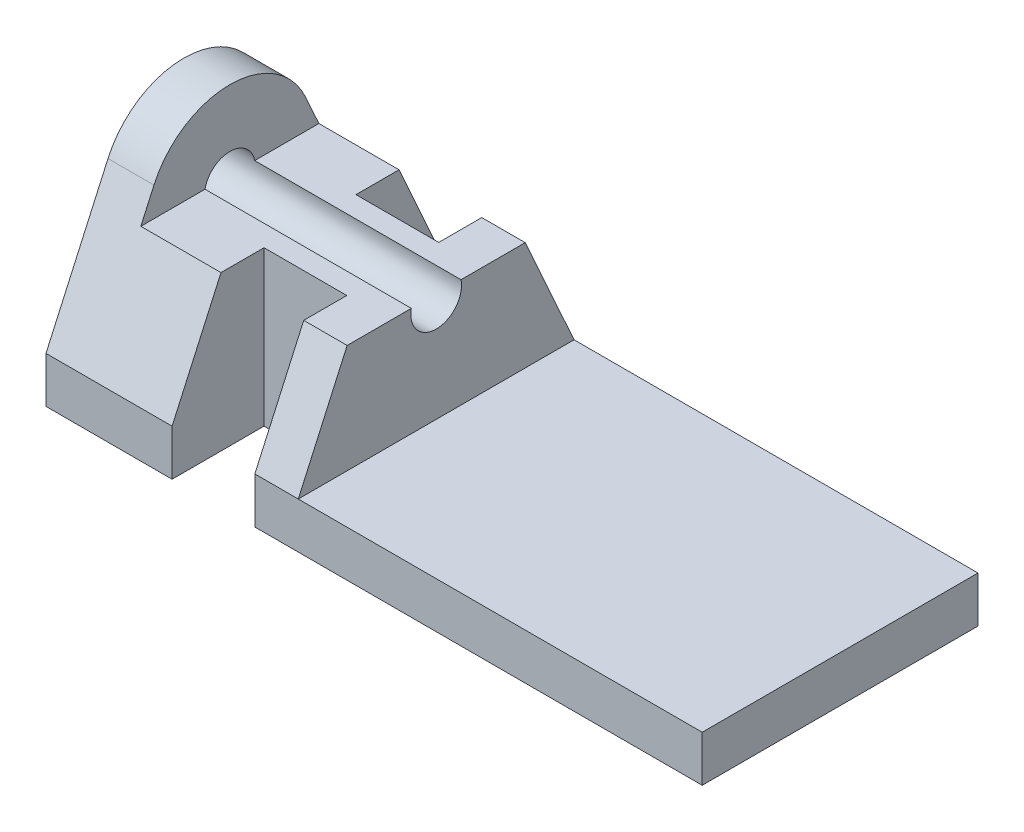
from build123d import *

# Parameters (mm, degrees)
SKETCH5_W                = 33.357089
SKETCH5_H                = 38.1
BOSS_EXTRUDE2_DEPTH      = 20.8
BOSS_EXTRUDE2_DEPTH_BACK = 69.85
SKETCH6_W                = 84.3
SKETCH6_H                = 27.007089
CUT_EXTRUDE1_DEPTH       = 39.1
SKETCH7_R                = 3.5
CUT_EXTRUDE2_DEPTH       = 21.8
CUT_EXTRUDE2_DEPTH_BACK  = 70.85
CUT_EXTRUDE3_DEPTH       = 70.85
SKETCH9_W                = 28.5
SKETCH9_H                = 38.1
BOSS_EXTRUDE3_DEPTH      = 15
CUT_EXTRUDE4_DEPTH       = 70.85
SKETCH11_R               = 3.5
CUT_EXTRUDE5_DEPTH       = 70.85
SKETCH13_W               = 11.43
SKETCH13_H               = 25.4
CUT_EXTRUDE6_DEPTH       = 26.807089
CUT_EXTRUDE6_DEPTH_BACK  = 7.35


with BuildPart() as part:
    # Sketch5 → Boss-Extrude2 (new body, two sides)
    with BuildSketch(Plane(origin=(0, 0, 0), x_dir=(0, -1, 0), z_dir=(1, 0, 0))) as boss_extrude2_sk:
        with Locations((-10.3285445, 0)):
            Rectangle(SKETCH5_W, SKETCH5_H)
    extrude(amount=BOSS_EXTRUDE2_DEPTH)
    extrude(boss_extrude2_sk.sketch, amount=-BOSS_EXTRUDE2_DEPTH_BACK)

    # Sketch6 → Cut-Extrude1 (cut, through all)
    with BuildSketch(Plane.XY.offset(19.05)):
        with Locations((-21.35, 13.5035445)):
            Rectangle(SKETCH6_W, SKETCH6_H)
    extrude(amount=-CUT_EXTRUDE1_DEPTH, mode=Mode.SUBTRACT)

    # Sketch7 → Cut-Extrude2 (cut, two sides)
    with BuildSketch(Plane(origin=(0, 0, 0), x_dir=(0, 0, -1), z_dir=(1, 0, 0))) as cut_extrude2_sk:
        with Locations((0, 14.307089)):
            Circle(SKETCH7_R)
    extrude(amount=CUT_EXTRUDE2_DEPTH, mode=Mode.SUBTRACT)
    extrude(cut_extrude2_sk.sketch, amount=-CUT_EXTRUDE2_DEPTH_BACK, mode=Mode.SUBTRACT)

    # Sketch8 → Cut-Extrude3 (cut, through all)
    with BuildSketch(Plane(origin=(0, 0, 0), x_dir=(0, 0, -1), z_dir=(1, 0, 0))):
        with BuildLine():
            Line((19.05, 0), (10.486875479, 19.026775715))
            ThreePointArc((10.486875479, 19.026775715), (0, 25.807089), (-10.486875479, 19.026775715))
            Line((-10.486875479, 19.026775715), (-19.05, 0))
            Line((-19.05, 0), (-19.05, 27.007089))
            Line((-19.05, 27.007089), (19.05, 27.007089))
            Line((19.05, 27.007089), (19.05, 0))
        make_face()
    extrude(amount=-CUT_EXTRUDE3_DEPTH, mode=Mode.SUBTRACT)

    # Sketch9 → Boss-Extrude3 (add)
    with BuildSketch(Plane(origin=(0, 0, 0), x_dir=(1, 0, 0), z_dir=(0, 1, 0))):
        with Locations((-49.25, 0)):
            Rectangle(SKETCH9_W, SKETCH9_H)
    extrude(amount=BOSS_EXTRUDE3_DEPTH)

    # Sketch10 → Cut-Extrude4 (cut, through all)
    with BuildSketch(Plane(origin=(0, 0, 0), x_dir=(0, 0, -1), z_dir=(1, 0, 0))):
        Polygon((19.05, 42.328016658), (19.05, 0), (0, 42.328016658), align=None)
        Polygon((-19.05, 42.328016658), (0, 42.328016658), (-19.05, 0), align=None)
    extrude(amount=-CUT_EXTRUDE4_DEPTH, mode=Mode.SUBTRACT)

    # Sketch11 → Cut-Extrude5 (cut, through all)
    with BuildSketch(Plane(origin=(0, 0, 0), x_dir=(0, 0, -1), z_dir=(1, 0, 0))):
        with Locations((0, 14.307089)):
            Circle(SKETCH11_R)
    extrude(amount=-CUT_EXTRUDE5_DEPTH, mode=Mode.SUBTRACT)

    # Sketch13 → Cut-Extrude6 (cut, two sides)
    with BuildSketch(Plane(origin=(0, 0, 0), x_dir=(1, 0, 0), z_dir=(0, 1, 0))) as cut_extrude6_sk:
        with Locations((-46.715, -19.05)):
            Rectangle(SKETCH13_W, SKETCH13_H)
        with Locations((-46.715, 19.05)):
            Rectangle(SKETCH13_W, SKETCH13_H)
    extrude(amount=CUT_EXTRUDE6_DEPTH, mode=Mode.SUBTRACT)
    extrude(cut_extrude6_sk.sketch, amount=-CUT_EXTRUDE6_DEPTH_BACK, mode=Mode.SUBTRACT)


solid = part.part
